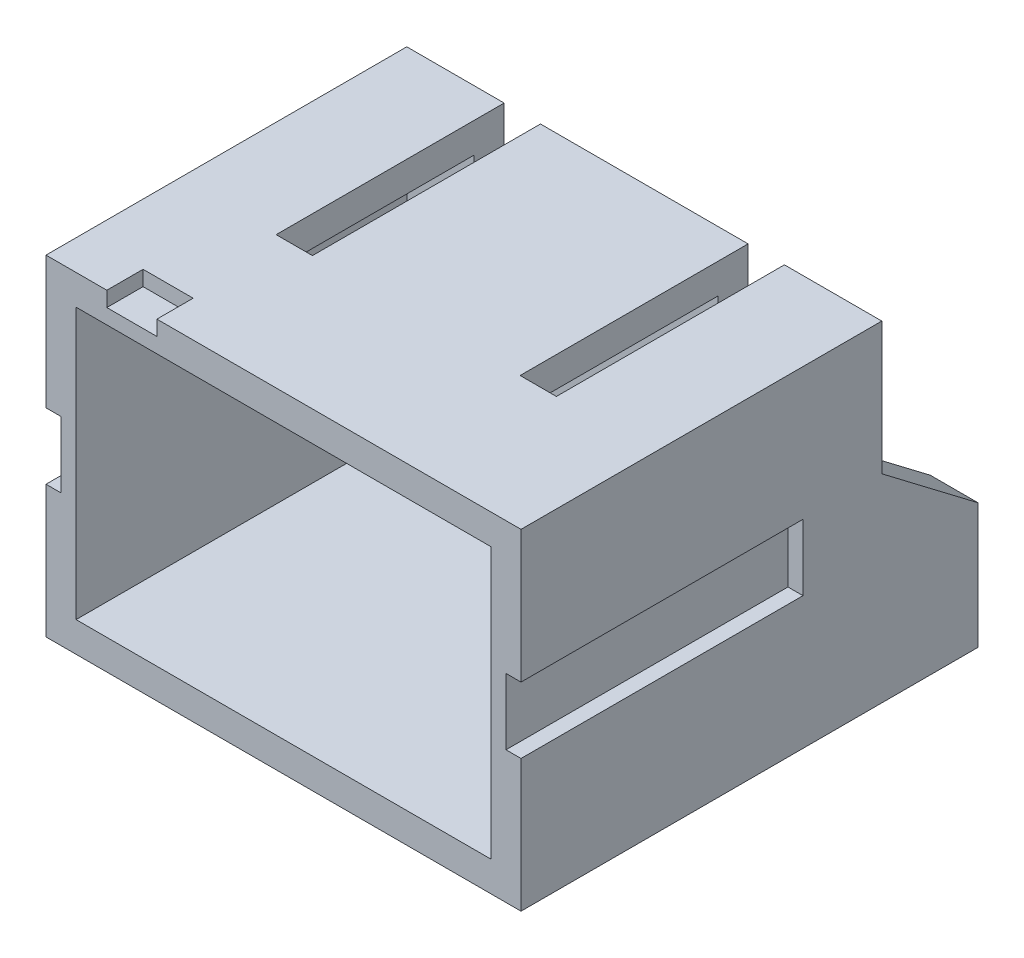
from build123d import *

# Parameters (mm, degrees)
BOSS_EXTRUDE1_DEPTH = 7.9
SKETCH4_W           = 6.315653724
SKETCH4_H           = 4.166384482
CUT_EXTRUDE2_DEPTH  = 1.6
SHELL1_T            = -0.5
SKETCH2_W           = 0.603812539
SKETCH2_H           = 7.583931724
CUT_EXTRUDE1_DEPTH  = 1.55
SKETCH5_W           = 0.832806424
SKETCH5_H           = 1.205065976
CUT_EXTRUDE3_DEPTH  = 0.25
SKETCH6_W           = 9.378889646
SKETCH6_H           = 1.1
CUT_EXTRUDE4_DEPTH  = 0.25


with BuildPart() as part:
    # Sketch1 → Boss-Extrude1 (new body)
    with BuildSketch(Plane(origin=(0, 0, 0), x_dir=(0, 0, -1), z_dir=(1, 0, 0))):
        Polygon((0, 0), (0, -3.3), (7.6, -3.3), (7.6, -1.216807759), (6, 0), (6, 2.2), (0, 2.2), align=None)
    extrude(amount=BOSS_EXTRUDE1_DEPTH)

    # Sketch4 → Cut-Extrude2 (cut)
    with BuildSketch(Plane(origin=(0, 0, -7.6), x_dir=(-1, 0, 0), z_dir=(0, 0, -1))):
        with Locations((-3.95, -1.216807759)):
            Rectangle(SKETCH4_W, SKETCH4_H)
    extrude(amount=-CUT_EXTRUDE2_DEPTH, mode=Mode.SUBTRACT)

    # Shell1
    shell1_openings = [part.faces().sort_by_distance(p)[0] for p in [
        (3.95, -0.55, 0),
    ]]
    offset(amount=SHELL1_T, openings=shell1_openings, kind=Kind.INTERSECTION)

    # Sketch2 → Cut-Extrude1 (cut)
    with BuildSketch(Plane(origin=(0, 2.2, 0), x_dir=(1, 0, 0), z_dir=(0, 1, 0))):
        with Locations((5.978601851, 6)):
            Rectangle(SKETCH2_W, SKETCH2_H)
        with Locations((1.92139815, 6)):
            Rectangle(SKETCH2_W, SKETCH2_H)
    extrude(amount=-CUT_EXTRUDE1_DEPTH, mode=Mode.SUBTRACT)

    # Sketch5 → Cut-Extrude3 (cut)
    with BuildSketch(Plane(origin=(0, 2.2, 0), x_dir=(1, 0, 0), z_dir=(0, 1, 0))):
        with Locations((1.428135285, 0)):
            Rectangle(SKETCH5_W, SKETCH5_H)
    extrude(amount=-CUT_EXTRUDE3_DEPTH, mode=Mode.SUBTRACT)

    # Sketch6 → Cut-Extrude4 (cut)
    with BuildSketch(Plane.ZY):
        with Locations((0, -0.55)):
            Rectangle(SKETCH6_W, SKETCH6_H)
    cut_extrude4 = extrude(amount=-CUT_EXTRUDE4_DEPTH, mode=Mode.SUBTRACT)

    # Mirror1: Cut-Extrude4 across plane
    add(cut_extrude4.mirror(Plane.ZY.offset(-3.95)), mode=Mode.SUBTRACT)


solid = part.part
